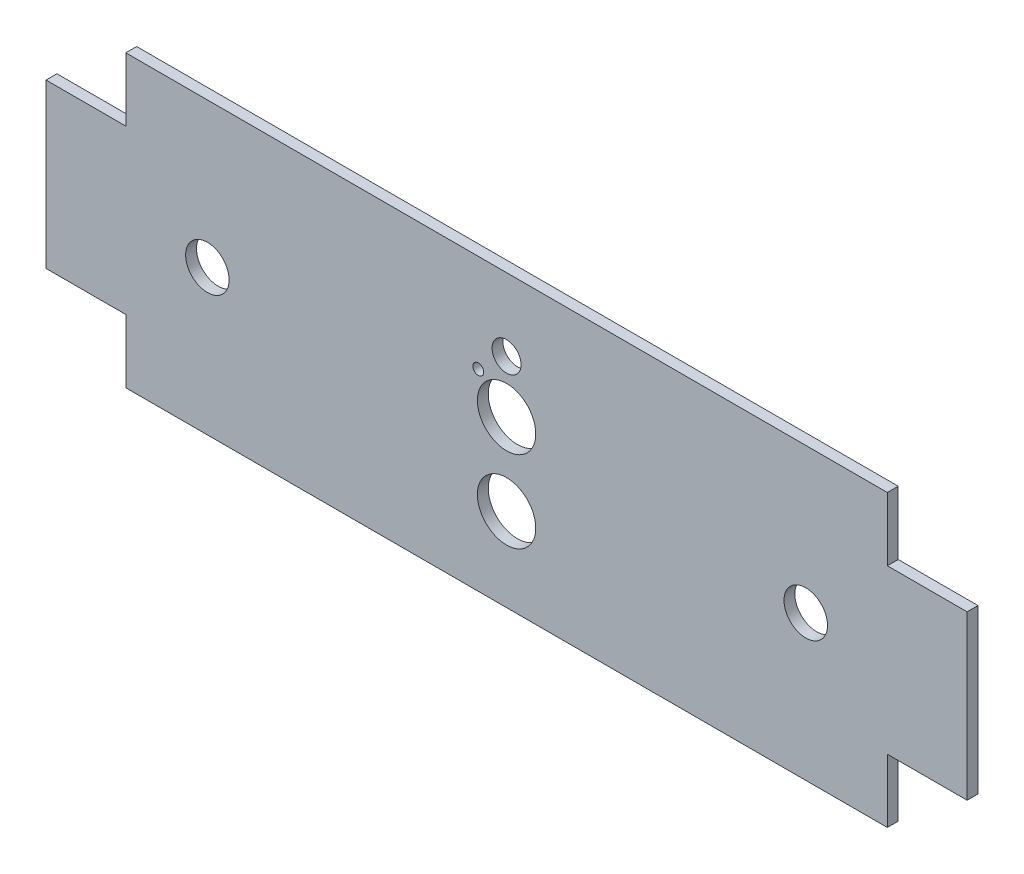
from build123d import *

# Parameters (mm, degrees)
CROQUIS1_W              = 22
CROQUIS1_H              = 45
CROQUIS1_W_2            = 210
CROQUIS1_H_2            = 60
SALIENTE_EXTRUIR1_DEPTH = 3
CORTAR_EXTRUIR1_REACH   = 5
CROQUIS2_R              = 6
CORTAR_EXTRUIR2_REACH   = 5
CROQUIS3_R              = 4
CROQUIS4_W              = 210
CROQUIS4_H              = 10
SALIENTE_EXTRUIR2_DEPTH = 3
CROQUIS5_W              = 210
CROQUIS5_H              = 10
SALIENTE_EXTRUIR3_DEPTH = 3
CORTAR_EXTRUIR3_REACH   = 5
CROQUIS6_R              = 1.5
CROQUIS6_R_2            = 8.05


with BuildPart() as part:
    # Croquis1 → Saliente-Extruir1 (new body)
    with BuildSketch(Plane.XY):
        with Locations((-116, 0)):
            Rectangle(CROQUIS1_W, CROQUIS1_H)
        Rectangle(CROQUIS1_W_2, CROQUIS1_H_2)
        with Locations((116, 0)):
            Rectangle(CROQUIS1_W, CROQUIS1_H)
    extrude(amount=SALIENTE_EXTRUIR1_DEPTH)

    # Croquis2 → Cortar-Extruir1 (cut, up to next)
    with BuildSketch(Plane.XY.offset(3), mode=Mode.PRIVATE) as cortar_extruir1_sk1:
        with Locations((82.5, 0)):
            Circle(CROQUIS2_R)
    cortar_extruir1_tool1 = extrude(cortar_extruir1_sk1.sketch, amount=-CORTAR_EXTRUIR1_REACH, mode=Mode.PRIVATE) & part.part
    add(cortar_extruir1_tool1.solids().sort_by_distance((82.5, 0, 3))[0], mode=Mode.SUBTRACT)
    # Croquis2 → Cortar-Extruir1 (cut, up to next)
    with BuildSketch(Plane.XY.offset(3), mode=Mode.PRIVATE) as cortar_extruir1_sk2:
        with Locations((-82.5, 0)):
            Circle(CROQUIS2_R)
    cortar_extruir1_tool2 = extrude(cortar_extruir1_sk2.sketch, amount=-CORTAR_EXTRUIR1_REACH, mode=Mode.PRIVATE) & part.part
    add(cortar_extruir1_tool2.solids().sort_by_distance((-82.5, 0, 3))[0], mode=Mode.SUBTRACT)

    # Croquis3 → Cortar-Extruir2 (cut, up to next)
    with BuildSketch(Plane.XY.offset(3), mode=Mode.PRIVATE) as cortar_extruir2_sk1:
        with Locations((0, 20)):
            Circle(CROQUIS3_R)
    cortar_extruir2_tool1 = extrude(cortar_extruir2_sk1.sketch, amount=-CORTAR_EXTRUIR2_REACH, mode=Mode.PRIVATE) & part.part
    add(cortar_extruir2_tool1.solids().sort_by_distance((0, 20, 3))[0], mode=Mode.SUBTRACT)

    # Croquis4 → Saliente-Extruir2 (add)
    with BuildSketch(Plane.XY.offset(3)):
        with Locations((0, -35)):
            Rectangle(CROQUIS4_W, CROQUIS4_H)
    extrude(amount=-SALIENTE_EXTRUIR2_DEPTH)

    # Croquis5 → Saliente-Extruir3 (add)
    with BuildSketch(Plane.XY.offset(3)):
        with Locations((0, 35)):
            Rectangle(CROQUIS5_W, CROQUIS5_H)
    extrude(amount=-SALIENTE_EXTRUIR3_DEPTH)

    # Croquis6 → Cortar-Extruir3 (cut, up to next)
    with BuildSketch(Plane.XY.offset(3), mode=Mode.PRIVATE) as cortar_extruir3_sk1:
        with Locations((-7.8, 13.05)):
            Circle(CROQUIS6_R)
    cortar_extruir3_tool1 = extrude(cortar_extruir3_sk1.sketch, amount=-CORTAR_EXTRUIR3_REACH, mode=Mode.PRIVATE) & part.part
    add(cortar_extruir3_tool1.solids().sort_by_distance((-7.8, 13.05, 3))[0], mode=Mode.SUBTRACT)
    # Croquis6 → Cortar-Extruir3 (cut, up to next)
    with BuildSketch(Plane.XY.offset(3), mode=Mode.PRIVATE) as cortar_extruir3_sk2:
        with Locations((0, 5.5)):
            Circle(CROQUIS6_R_2)
    cortar_extruir3_tool2 = extrude(cortar_extruir3_sk2.sketch, amount=-CORTAR_EXTRUIR3_REACH, mode=Mode.PRIVATE) & part.part
    add(cortar_extruir3_tool2.solids().sort_by_distance((0, 5.5, 3))[0], mode=Mode.SUBTRACT)
    # Croquis6 → Cortar-Extruir3 (cut, up to next)
    with BuildSketch(Plane.XY.offset(3), mode=Mode.PRIVATE) as cortar_extruir3_sk3:
        with Locations((0, -17)):
            Circle(CROQUIS6_R_2)
    cortar_extruir3_tool3 = extrude(cortar_extruir3_sk3.sketch, amount=-CORTAR_EXTRUIR3_REACH, mode=Mode.PRIVATE) & part.part
    add(cortar_extruir3_tool3.solids().sort_by_distance((0, -17, 3))[0], mode=Mode.SUBTRACT)


solid = part.part
